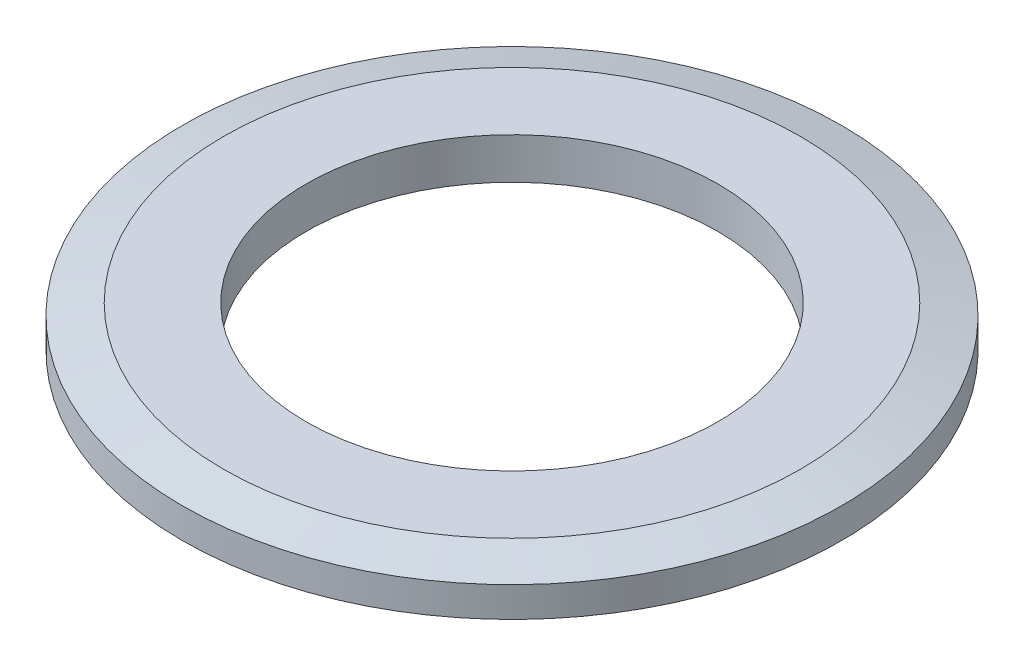
from build123d import *

# Parameters (mm, degrees)
SKETCH1_R           = 8
SKETCH1_R_2         = 5
BOSS_EXTRUDE1_DEPTH = 1
CHAMFER1_SIZE       = 1
CHAMFER1_SIZE2      = 0.267949192


with BuildPart() as part:
    # Sketch1 → Boss-Extrude1 (new body)
    with BuildSketch(Plane(origin=(0, 0, 0), x_dir=(1, 0, 0), z_dir=(0, 1, 0))):
        Circle(SKETCH1_R)
        Circle(SKETCH1_R_2, mode=Mode.SUBTRACT)
    extrude(amount=BOSS_EXTRUDE1_DEPTH)

    # Chamfer1
    chamfer1_edges = [part.edges().sort_by_distance(p)[0] for p in [
        (-8, 1, 0),
    ]]
    chamfer1_side = [part.faces().sort_by_distance(p)[0] for p in [
        (-7.77372583, 1, 0),
    ]]
    chamfer(chamfer1_edges, length=CHAMFER1_SIZE, length2=CHAMFER1_SIZE2, reference=chamfer1_side[0])


solid = part.part
